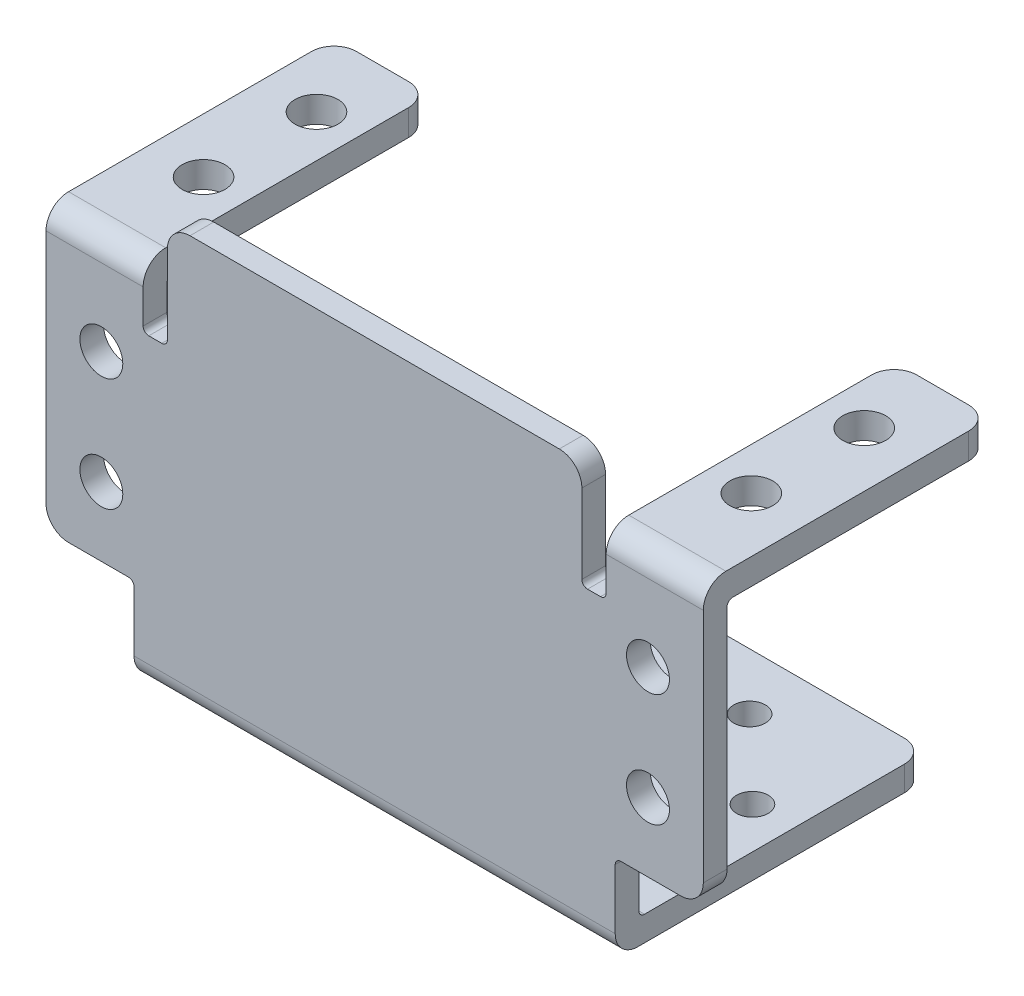
from build123d import *

# Parameters (mm, degrees)
BOSS_EXTRUDE1_DEPTH = 29.1
CUT_EXTRUDE1_DEPTH  = 9.5
SKETCH3_W           = 8.6
SKETCH3_H           = 25.5
CUT_EXTRUDE2_DEPTH  = 4
SKETCH4_W           = 7.8
SKETCH4_H           = 27.6
CUT_EXTRUDE3_DEPTH  = 7.8
SKETCH5_R           = 1.9
CUT_EXTRUDE4_DEPTH  = 2.3
SKETCH6_R           = 1.9
CUT_EXTRUDE5_DEPTH  = 2.1
FILLET_2MM_R        = 2
FILLET2_R           = 0.5
SKETCH7_R           = 1.4
CUT_EXTRUDE6_DEPTH  = 2.2


with BuildPart() as part:
    # Sketch1 → Boss-Extrude1 (new body, symmetric)
    with BuildSketch(Plane(origin=(0, 0, 0), x_dir=(0, 0, -1), z_dir=(1, 0, 0))):
        Polygon((0, 0), (0, 36.7), (25.5, 36.7), (25.5, 30.4), (2.1, 30.4), (2.1, 2.2), (27.6, 2.2), (27.6, 0), align=None)
    extrude(amount=BOSS_EXTRUDE1_DEPTH, both=True)

    # Sketch2 → Cut-Extrude1 (cut)
    with BuildSketch(Plane(origin=(0, 36.7, 0), x_dir=(1, 0, 0), z_dir=(0, 1, 0))):
        Polygon((-18.35, 2.1), (18.35, 2.1), (18.35, 0), (20.5, 0), (20.5, 25.5), (-20.5, 25.5), (-20.5, 0), (-18.35, 0), align=None)
    extrude(amount=-CUT_EXTRUDE1_DEPTH, mode=Mode.SUBTRACT)

    # Sketch3 → Cut-Extrude2 (cut)
    with BuildSketch(Plane(origin=(0, 36.7, 0), x_dir=(1, 0, 0), z_dir=(0, 1, 0))):
        with Locations((24.8, 12.75)):
            Rectangle(SKETCH3_W, SKETCH3_H)
        with Locations((-24.8, 12.75)):
            Rectangle(SKETCH3_W, SKETCH3_H)
    extrude(amount=-CUT_EXTRUDE2_DEPTH, mode=Mode.SUBTRACT)

    # Sketch4 → Cut-Extrude3 (cut)
    with BuildSketch(Plane.XZ):
        with Locations((-25.2, -13.8)):
            Rectangle(SKETCH4_W, SKETCH4_H)
        with Locations((25.2, -13.8)):
            Rectangle(SKETCH4_W, SKETCH4_H)
    extrude(amount=-CUT_EXTRUDE3_DEPTH, mode=Mode.SUBTRACT)

    # Sketch5 → Cut-Extrude4 (cut)
    with BuildSketch(Plane(origin=(0, 32.7, 0), x_dir=(1, 0, 0), z_dir=(0, 1, 0))):
        with Locations((-24.25, 19.1)):
            Circle(SKETCH5_R)
        with Locations((-24.25, 9.1)):
            Circle(SKETCH5_R)
        with Locations((24.25, 9.1)):
            Circle(SKETCH5_R)
        with Locations((24.25, 19.1)):
            Circle(SKETCH5_R)
    extrude(amount=-CUT_EXTRUDE4_DEPTH, mode=Mode.SUBTRACT)

    # Sketch6 → Cut-Extrude5 (cut)
    with BuildSketch(Plane.XY):
        with Locations((24.2, 23.9)):
            Circle(SKETCH6_R)
        with Locations((24.2, 13.9)):
            Circle(SKETCH6_R)
        with Locations((-24.2, 13.9)):
            Circle(SKETCH6_R)
        with Locations((-24.2, 23.9)):
            Circle(SKETCH6_R)
    extrude(amount=-CUT_EXTRUDE5_DEPTH, mode=Mode.SUBTRACT)

    # Fillet 2mm
    fillet_2mm_edges = [part.edges().sort_by_distance(p)[0] for p in [
        (0, 0, 0),
        (-21.3, 1.1, -27.6),
        (-29.1, 7.8, -1.05),
        (29.1, 7.8, -1.05),
        (21.3, 1.1, -27.6),
        (29.1, 31.55, -25.5),
        (-20.5, 31.55, -25.5),
        (20.5, 31.55, -25.5),
        (-18.35, 36.7, -1.05),
        (18.35, 36.7, -1.05),
        (24.8, 32.7, 0),
        (-24.8, 32.7, 0),
        (-29.1, 31.55, -25.5),
    ]]
    fillet(fillet_2mm_edges, radius=FILLET_2MM_R)

    # Fillet2
    fillet2_edges = [part.edges().sort_by_distance(p)[0] for p in [
        (0, 2.2, -2.1),
        (-21.3, 7.8, -1.05),
        (21.3, 7.8, -1.05),
        (24.8, 30.4, -2.1),
        (-24.8, 30.4, -2.1),
        (20.5, 27.2, -1.05),
        (-20.5, 27.2, -1.05),
        (18.35, 27.2, -1.05),
        (-18.35, 27.2, -1.05),
    ]]
    fillet(fillet2_edges, radius=FILLET2_R)

    # Sketch7 → Cut-Extrude6 (cut)
    with BuildSketch(Plane(origin=(0, 2.2, 0), x_dir=(1, 0, 0), z_dir=(0, 1, 0))):
        with Locations((10.6, 22.6)):
            Circle(SKETCH7_R)
        with Locations((10.6, 9)):
            Circle(SKETCH7_R)
        with Locations((10.6, 15.8)):
            Circle(SKETCH7_R)
        with Locations((3.55, 15.8)):
            Circle(SKETCH7_R)
        with Locations((17.65, 15.8)):
            Circle(SKETCH7_R)
        with Locations((-17.65, 15.8)):
            Circle(SKETCH7_R)
        with Locations((-3.55, 15.8)):
            Circle(SKETCH7_R)
        with Locations((-10.6, 15.8)):
            Circle(SKETCH7_R)
        with Locations((-10.6, 9)):
            Circle(SKETCH7_R)
        with Locations((-10.6, 22.6)):
            Circle(SKETCH7_R)
    extrude(amount=-CUT_EXTRUDE6_DEPTH, mode=Mode.SUBTRACT)


solid = part.part
